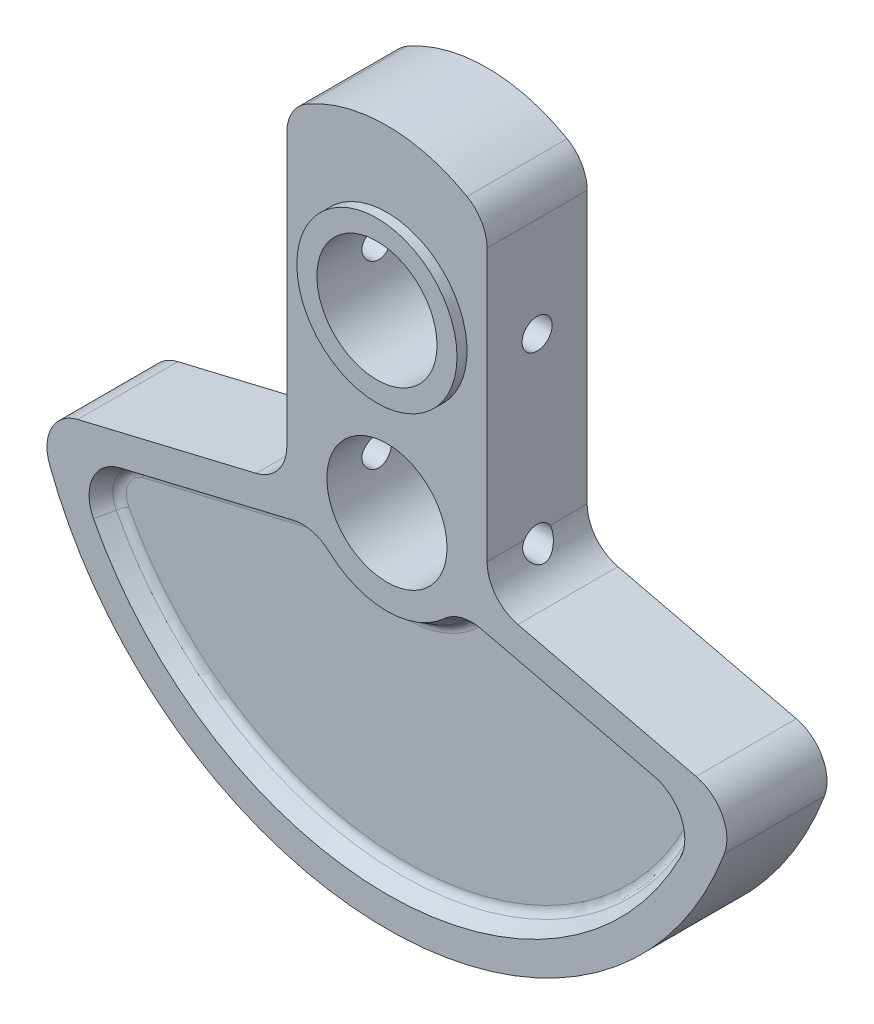
from build123d import *
from build123d.topology import SkipClean

# Parameters (mm, degrees)
BOSS_EXTRUDE1_DEPTH      = 2.5
BOSS_EXTRUDE1_DEPTH_BACK = 2.5
CUT_EXTRUDE1_DEPTH       = 1
CUT_EXTRUDE1_DRAFT       = -30
MIRROR1_COPY_1_DEPTH     = 1
MIRROR1_COPY_1_DRAFT     = -30
SKETCH4_R                = 3
CUT_EXTRUDE3_DEPTH       = 26.244307592
SKETCH7_R                = 4
SKETCH7_R_2              = 3
BOSS_EXTRUDE3_DEPTH      = 0.5
SKETCH8_R                = 3
CUT_EXTRUDE4_DEPTH       = 26.348078148
BOSS_EXTRUDE4_START      = 0.5
SKETCH9_R                = 4
SKETCH9_R_2              = 3
BOSS_EXTRUDE4_DEPTH      = 0.5
CUT_EXTRUDE5_DEPTH       = 29.56679394
CUT_EXTRUDE5_DEPTH_BACK  = 29.56679394
SKETCH10_R               = 0.75
FILLET1_R                = 0.5
FILLET2_R                = 0.5


with BuildPart() as part:
    # Sketch2 → Boss-Extrude1 (new, two sides: drawn at the far end of the back side and taken through both)
    with BuildSketch(Plane.XY.offset(-BOSS_EXTRUDE1_DEPTH_BACK)):
        with BuildLine():
            Line((-15.442222224, -3.67937125), (-6.536442795, -1.557418314))
            ThreePointArc((-6.536442795, -1.557418314), (-5.4304277, -0.851414482), (-5, 0.388118815))
            Line((-5, 0.388118815), (-5, 13.951154424))
            ThreePointArc((-5, 13.951154424), (-4.732050808, 14.951154424), (-4, 15.683205232))
            ThreePointArc((-4, 15.683205232), (0, 16.755002002), (4, 15.683205232))
            ThreePointArc((4, 15.683205232), (4.732050808, 14.951154424), (5, 13.951154424))
            Line((5, 13.951154424), (5, 0.388118815))
            ThreePointArc((5, 0.388118815), (5.4304277, -0.851414482), (6.536442795, -1.557418314))
            Line((6.536442795, -1.557418314), (15.442222224, -3.67937125))
            ThreePointArc((15.442222224, -3.67937125), (16.744432136, -4.68572443), (16.850998146, -6.328021925))
            ThreePointArc((16.850998146, -6.328021925), (0, -18), (-16.850998146, -6.328021925))
            ThreePointArc((-16.850998146, -6.328021925), (-16.744432136, -4.68572443), (-15.442222224, -3.67937125))
        make_face()
    extrude(amount=BOSS_EXTRUDE1_DEPTH + BOSS_EXTRUDE1_DEPTH_BACK)


with BuildPart() as cut_extrude1_tool:
    # Sketch3 → Cut-Extrude1 (with draft: the straight prism first)
    with BuildSketch(Plane.XY.offset(2.5)):
        with BuildLine():
            ThreePointArc((-13.340399108, -4.720566877), (-14.695107573, -5.833091429), (-14.652958027, -7.585566627))
            ThreePointArc((-14.652958027, -7.585566627), (0, -16.5), (14.652958027, -7.585566627))
            ThreePointArc((14.652958027, -7.585566627), (14.695107573, -5.833091429), (13.340399108, -4.720566877))
            Line((13.340399108, -4.720566877), (4.68940437, -2.659320713))
            ThreePointArc((4.68940437, -2.659320713), (3.722712002, -2.669178372), (2.873576072, -3.131303332))
            ThreePointArc((2.873576072, -3.131303332), (0, -4.25), (-2.873576072, -3.131303332))
            ThreePointArc((-2.873576072, -3.131303332), (-3.722712002, -2.669178372), (-4.68940437, -2.659320713))
            Line((-4.68940437, -2.659320713), (-13.340399108, -4.720566877))
        make_face()
    extrude(amount=-CUT_EXTRUDE1_DEPTH)
    # Cut-Extrude1: the draft: its side faces are tilted about the plane it starts from
    cut_extrude1_sides = [cut_extrude1_tool.faces().sort_by_distance(p)[0] for p in [
        (0, -4.25, 2),
        (-3.722712002, -2.669178372, 2),
        (-9.014901739, -3.689943795, 2),
        (-14.695107573, -5.833091429, 2),
        (0, -16.5, 2),
        (14.695107573, -5.833091429, 2),
        (9.014901739, -3.689943795, 2),
        (3.722712002, -2.669178372, 2),
    ]]
    draft(cut_extrude1_sides, Plane.XY.offset(2.5), CUT_EXTRUDE1_DRAFT)


with BuildPart() as part_1:
    add(part.part)

    # Cut-Extrude1: cut by cut_extrude1_tool
    add(cut_extrude1_tool.part, mode=Mode.SUBTRACT)


with BuildPart() as mirror1_copy_1_tool:
    # Mirror1 copy 1 sketch → Mirror1 copy 1 (with draft: the straight prism first)
    with BuildSketch(Plane(origin=(0, 0, -2.5), x_dir=(1, 0, 0), z_dir=(0, 0, -1))):
        with BuildLine():
            ThreePointArc((-13.340399108, 4.720566877), (-14.695107573, 5.833091429), (-14.652958027, 7.585566627))
            ThreePointArc((-14.652958027, 7.585566627), (0, 16.5), (14.652958027, 7.585566627))
            ThreePointArc((14.652958027, 7.585566627), (14.695107573, 5.833091429), (13.340399108, 4.720566877))
            Line((13.340399108, 4.720566877), (4.68940437, 2.659320713))
            ThreePointArc((4.68940437, 2.659320713), (3.722712002, 2.669178372), (2.873576072, 3.131303332))
            ThreePointArc((2.873576072, 3.131303332), (0, 4.25), (-2.873576072, 3.131303332))
            ThreePointArc((-2.873576072, 3.131303332), (-3.722712002, 2.669178372), (-4.68940437, 2.659320713))
            Line((-4.68940437, 2.659320713), (-13.340399108, 4.720566877))
        make_face()
    extrude(amount=-MIRROR1_COPY_1_DEPTH)
    # Mirror1 copy 1: the draft: its side faces are tilted about the plane it starts from
    mirror1_copy_1_sides = [mirror1_copy_1_tool.faces().sort_by_distance(p)[0] for p in [
        (0, -4.25, -2),
        (-3.722712002, -2.669178372, -2),
        (-9.014901739, -3.689943795, -2),
        (-14.695107573, -5.833091429, -2),
        (0, -16.5, -2),
        (14.695107573, -5.833091429, -2),
        (9.014901739, -3.689943795, -2),
        (3.722712002, -2.669178372, -2),
    ]]
    draft(mirror1_copy_1_sides, Plane(origin=(0, 0, -2.5), x_dir=(1, 0, 0), z_dir=(0, 0, -1)), MIRROR1_COPY_1_DRAFT)


with BuildPart() as part_2:
    add(part_1.part)

    # Mirror1 copy 1: cut by mirror1_copy_1_tool
    add(mirror1_copy_1_tool.part, mode=Mode.SUBTRACT)

    # Sketch4 → Cut-Extrude3 (cut, through all)
    with BuildSketch(Plane.XY.offset(2.5)):
        Circle(SKETCH4_R)
    extrude(amount=-CUT_EXTRUDE3_DEPTH, mode=Mode.SUBTRACT)

    # Sketch7 → Boss-Extrude3 (add)
    with SkipClean():  # the faces are left unmerged after this step: merging them gives an invalid solid
        with BuildSketch(Plane(origin=(0, 0, -2.5), x_dir=(-1, 0, 0), z_dir=(0, 0, -1))):
            Circle(SKETCH7_R)
            Circle(SKETCH7_R_2, mode=Mode.SUBTRACT)
        extrude(amount=BOSS_EXTRUDE3_DEPTH)

    # Sketch8 → Cut-Extrude4 (cut, through all)
    with SkipClean():  # the faces are left unmerged after this step: merging them gives an invalid solid
        with BuildSketch(Plane.XY.offset(2.5)):
            with Locations((0, 9)):
                Circle(SKETCH8_R)
        extrude(amount=-CUT_EXTRUDE4_DEPTH, mode=Mode.SUBTRACT)

    # Sketch9 → Boss-Extrude4 (add)
    with SkipClean():  # the faces are left unmerged after this step: merging them gives an invalid solid
        with BuildSketch(Plane.XY.offset(2.5).offset(BOSS_EXTRUDE4_START)):
            with Locations((0, 9)):
                Circle(SKETCH9_R)
            with Locations((0, 9)):
                Circle(SKETCH9_R_2, mode=Mode.SUBTRACT)
        extrude(amount=-BOSS_EXTRUDE4_DEPTH)

    # Sketch10 → Cut-Extrude5 (cut, two sides: drawn at the far end of the back side and taken through both)
    with BuildSketch(Plane.ZY.offset(5).offset(-CUT_EXTRUDE5_DEPTH_BACK)):
        with Locations((0, 9)):
            Circle(SKETCH10_R)
        Circle(SKETCH10_R)
    extrude(amount=CUT_EXTRUDE5_DEPTH + CUT_EXTRUDE5_DEPTH_BACK, mode=Mode.SUBTRACT)

    # Fillet1
    fillet1_edges = [part_2.edges().sort_by_distance(p)[0] for p in [
        (-14.170219486, -6.073561446, 1.5),
        (-8.8810843, -4.251571987, 1.5),
        (-3.867954613, -3.227960903, 1.5),
        (0, -4.827350269, 1.5),
        (3.867954613, -3.227960903, 1.5),
        (8.8810843, -4.251571987, 1.5),
        (14.170219486, -6.073561446, 1.5),
        (0, -15.922649731, 1.5),
    ]]
    fillet(fillet1_edges, radius=FILLET1_R)

    # Fillet2
    fillet2_edges = [part_2.edges().sort_by_distance(p)[0] for p in [
        (0, -4.827350269, -1.5),
    ]]
    fillet(fillet2_edges, radius=FILLET2_R)


solid = part_2.part
